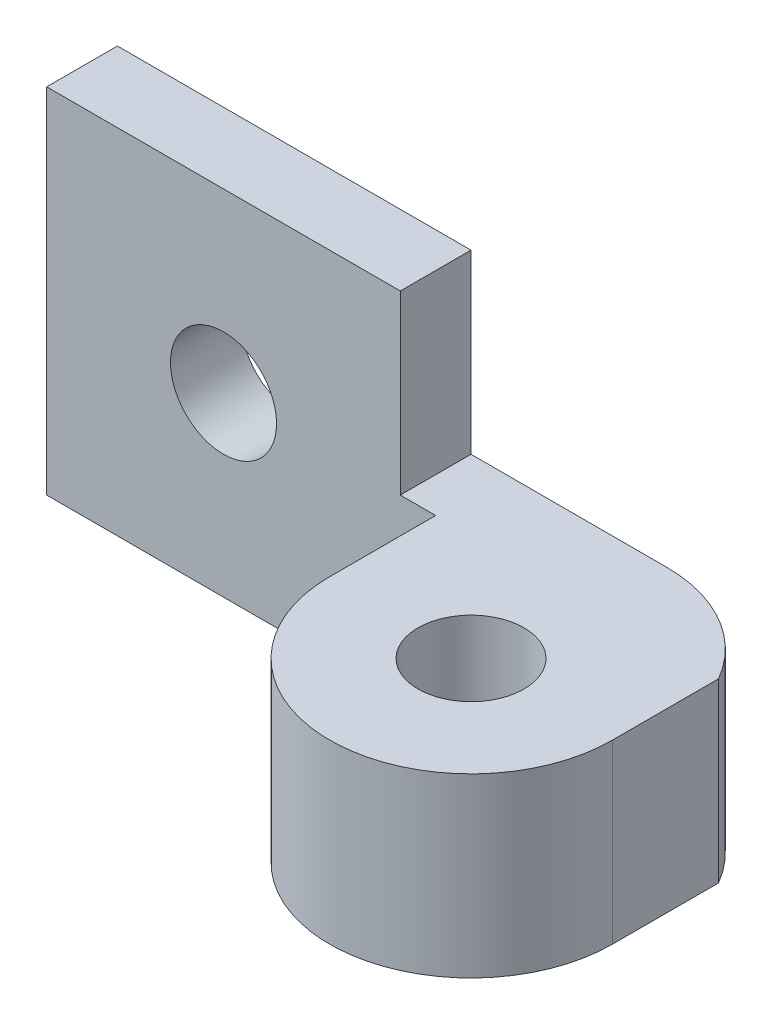
from build123d import *

# Parameters (mm, degrees)
ESQUISSE1_R        = 1.5
BOSS_EXTRU_2_DEPTH = 2
ESQUISSE4_R        = 1.5
BOSS_EXTRU_3_DEPTH = 5


with BuildPart() as part:
    # Esquisse1 → Boss.-Extru.2 (new body)
    with BuildSketch(Plane.XY):
        Polygon((0, 0), (15, 0), (15, 5), (10, 5), (10, 10), (0, 10), align=None)
        with Locations((5, 5)):
            Circle(ESQUISSE1_R, mode=Mode.SUBTRACT)
    extrude(amount=BOSS_EXTRU_2_DEPTH)

    # Esquisse4 → Boss.-Extru.3 (add)
    with BuildSketch(Plane.XZ):
        with BuildLine():
            Line((11, 5), (11, 0))
            Line((11, 0), (15.535898385, 0))
            ThreePointArc((15.535898385, 0), (17.535898385, 0.535898385), (19, 2))
            Line((19, 2), (19, 5))
            ThreePointArc((19, 5), (15, 9), (11, 5))
        make_face()
        with Locations((15, 5)):
            Circle(ESQUISSE4_R, mode=Mode.SUBTRACT)
    extrude(amount=-BOSS_EXTRU_3_DEPTH)


solid = part.part
